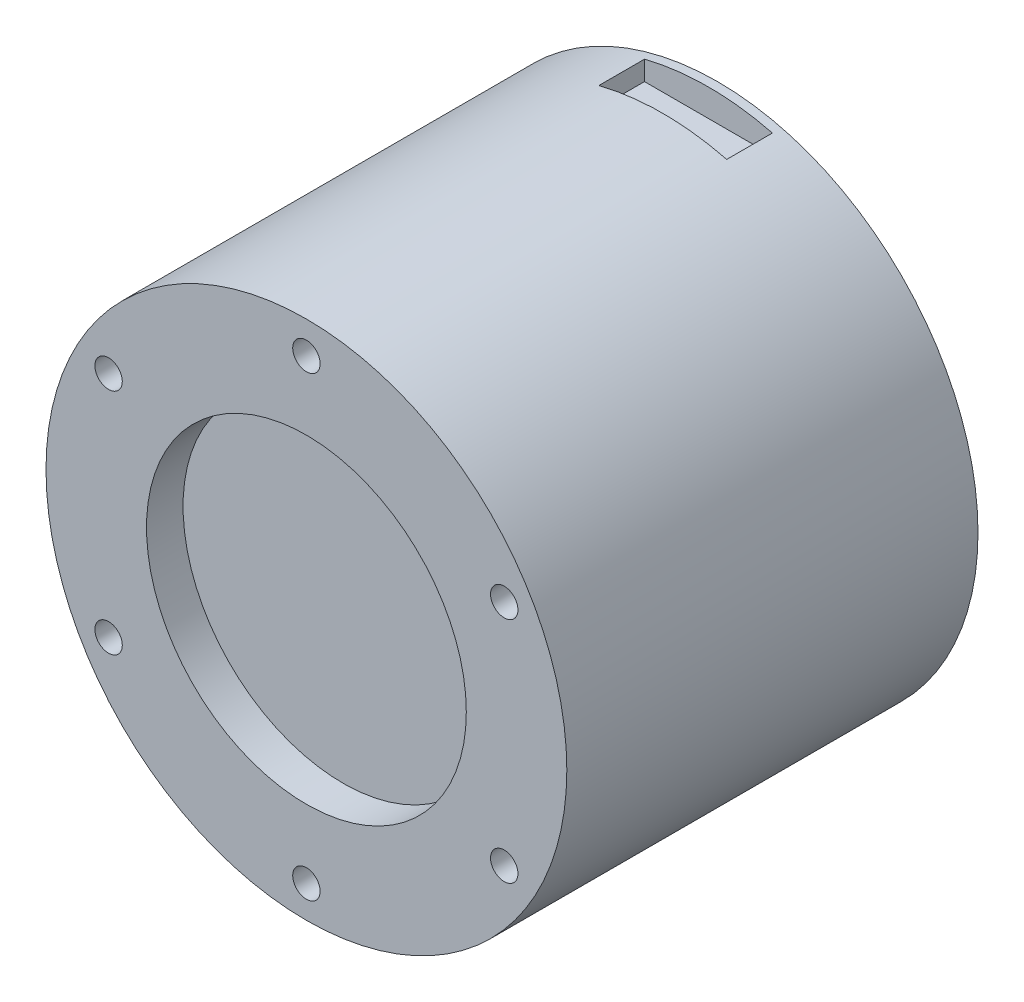
from build123d import *

# Parameters (mm, degrees)
SKETCH_1_R          = 28.5
EXTRUDE_1_DEPTH     = 45
SKETCH_2_R          = 17.5
CUT_EXTRUDE_2_DEPTH = 4
SKETCH_2_5_R        = 1.5
CUT_EXTRUDE_3_DEPTH = 5
SKETCH_4_R          = 1.5
CUT_EXTRUDE_4_DEPTH = 4
SKETCH_9_W          = 14
SKETCH_9_H          = 5
CUT_EXTRUDE_6_DEPTH = 3
SKETCH_10_W         = 8
SKETCH_10_H         = 8
CUT_EXTRUDE_7_DEPTH = 3


with BuildPart() as part:
    # 草图1 → 凸台-拉伸1 (new body)
    with BuildSketch(Plane.XY):
        Circle(SKETCH_1_R)
    extrude(amount=EXTRUDE_1_DEPTH)

    # 草图2 → 切除-拉伸2 (cut)
    with BuildSketch(Plane.XY.offset(45)):
        Circle(SKETCH_2_R)
    extrude(amount=-CUT_EXTRUDE_2_DEPTH, mode=Mode.SUBTRACT)

    # 草图2<5> → 切除-拉伸3 (cut)
    with BuildSketch(Plane.XY.offset(45)):
        with Locations((0, 25)):
            Circle(SKETCH_2_5_R)
        with Locations((21.650635095, 12.5)):
            Circle(SKETCH_2_5_R)
        with Locations((21.650635095, -12.5)):
            Circle(SKETCH_2_5_R)
        with Locations((0, -25)):
            Circle(SKETCH_2_5_R)
        with Locations((-21.650635095, -12.5)):
            Circle(SKETCH_2_5_R)
        with Locations((-21.650635095, 12.5)):
            Circle(SKETCH_2_5_R)
    extrude(amount=-CUT_EXTRUDE_3_DEPTH, mode=Mode.SUBTRACT)

    # 草图4 → 切除-拉伸4 (cut)
    with BuildSketch(Plane(origin=(0, 0, 0), x_dir=(-1, 0, 0), z_dir=(0, 0, -1))):
        with Locations((13.435028843, 13.435028843)):
            Circle(SKETCH_4_R)
        with Locations((-13.435028843, 13.435028843)):
            Circle(SKETCH_4_R)
        with Locations((13.435028843, -13.435028843)):
            Circle(SKETCH_4_R)
        with Locations((-13.435028843, -13.435028843)):
            Circle(SKETCH_4_R)
    extrude(amount=-CUT_EXTRUDE_4_DEPTH, mode=Mode.SUBTRACT)

    # 草图9 → 切除-拉伸6 (cut)
    with BuildSketch(Plane(origin=(0, 28.5, 0), x_dir=(1, 0, 0), z_dir=(0, 1, 0))):
        with Locations((0, -3.5)):
            Rectangle(SKETCH_9_W, SKETCH_9_H)
    cut_extrude_6 = extrude(amount=-CUT_EXTRUDE_6_DEPTH, mode=Mode.SUBTRACT)

    # 镜向1: 切除-拉伸6 across plane
    add(cut_extrude_6.mirror(Plane.ZX), mode=Mode.SUBTRACT)

    # 草图10 → 切除-拉伸7 (cut)
    with BuildSketch(Plane(origin=(-28.5, 0, 0), x_dir=(0, 0, -1), z_dir=(1, 0, 0))):
        with Locations((-5, 0)):
            Rectangle(SKETCH_10_W, SKETCH_10_H)
    extrude(amount=CUT_EXTRUDE_7_DEPTH, mode=Mode.SUBTRACT)


solid = part.part
